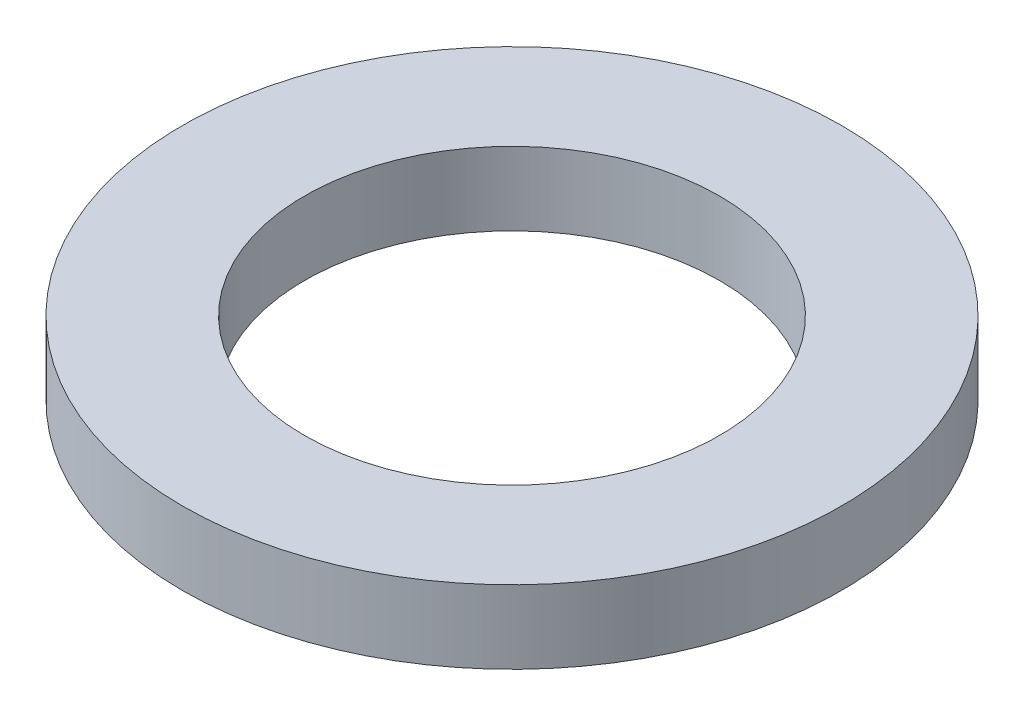
from build123d import *

# Parameters (mm, degrees)
SKETCH1_R           = 13.5
SKETCH1_R_2         = 8.5
BOSS_EXTRUDE1_DEPTH = 3


with BuildPart() as part:
    # Sketch1 → Boss-Extrude1 (new body)
    with BuildSketch(Plane(origin=(0, 0, 0), x_dir=(1, 0, 0), z_dir=(0, 1, 0))):
        Circle(SKETCH1_R)
        Circle(SKETCH1_R_2, mode=Mode.SUBTRACT)
    extrude(amount=BOSS_EXTRUDE1_DEPTH)


solid = part.part
